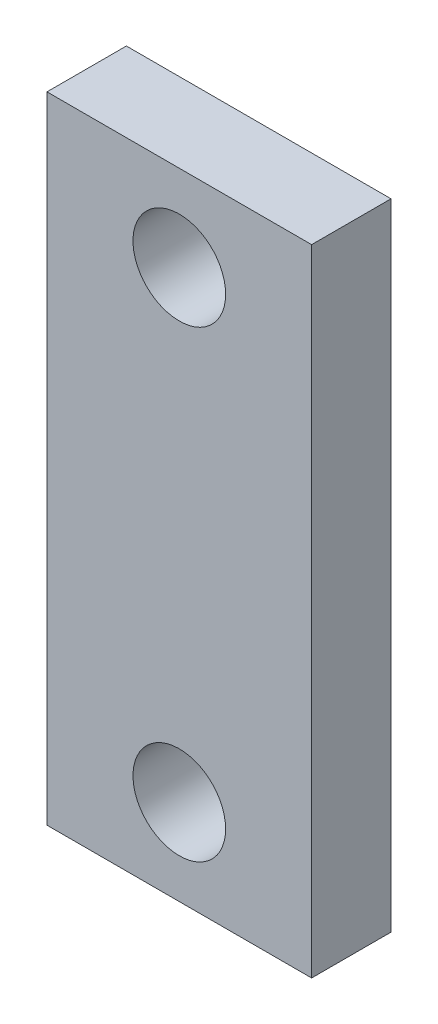
from build123d import *

# Parameters (mm, degrees)
CROQUIS1_W              = 10
CROQUIS1_H              = 24
CROQUIS1_R              = 1.75
SALIENTE_EXTRUIR1_DEPTH = 3


with BuildPart() as part:
    # Croquis1 → Saliente-Extruir1 (new body)
    with BuildSketch(Plane.XY):
        Rectangle(CROQUIS1_W, CROQUIS1_H)
        with Locations((0, 8.75)):
            Circle(CROQUIS1_R, mode=Mode.SUBTRACT)
        with Locations((0, -8.75)):
            Circle(CROQUIS1_R, mode=Mode.SUBTRACT)
    extrude(amount=SALIENTE_EXTRUIR1_DEPTH)


solid = part.part
